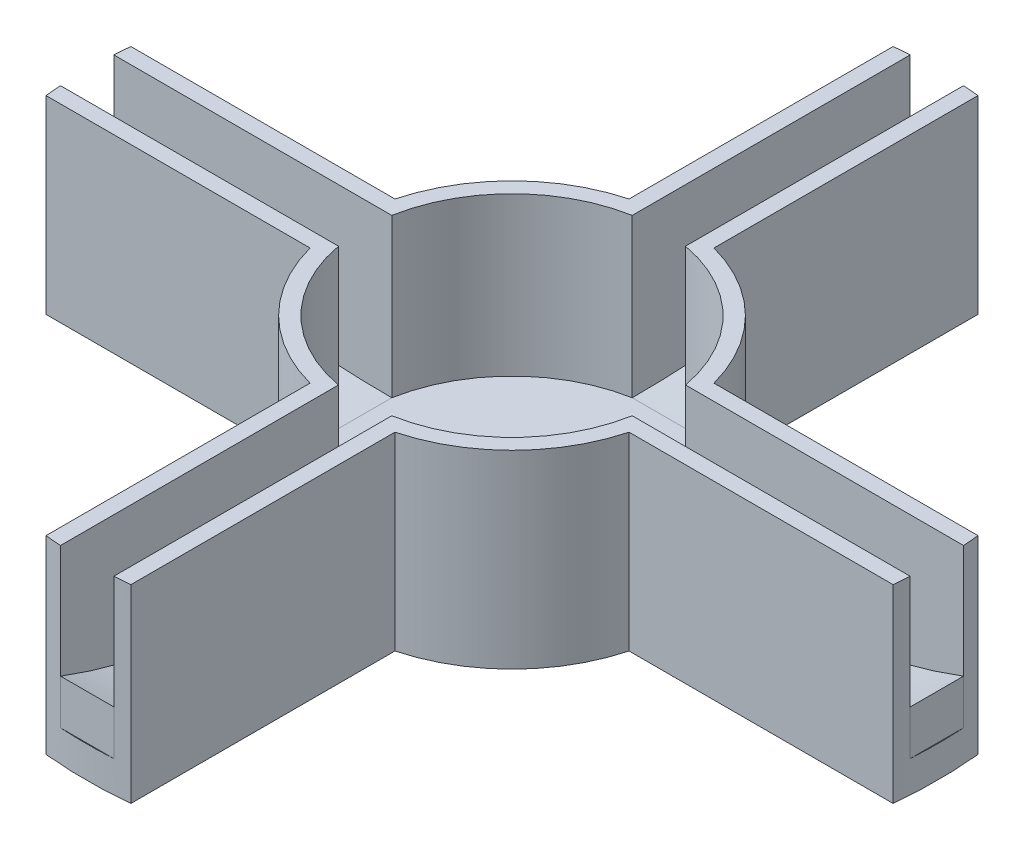
from build123d import *

# Parameters (mm, degrees)
SKETCH2_R           = 26.95
SKETCH2_R_2         = 9.45
BOSS_EXTRUDE2_DEPTH = 10
SKETCH3_R           = 26.95
BOSS_EXTRUDE3_DEPTH = 2
CUT_EXTRUDE1_DEPTH  = 10
BOSS_EXTRUDE4_DEPTH = 3.375
CIRPATTERN1_COUNT   = 4
CUT_EXTRUDE2_DEPTH  = 12
CIRPATTERN2_COUNT   = 4


with BuildPart() as part:
    # Sketch2 → Boss-Extrude2 (new body)
    with BuildSketch(Plane(origin=(0, 0, 0), x_dir=(1, 0, 0), z_dir=(0, 1, 0))):
        Circle(SKETCH2_R)
        Circle(SKETCH2_R_2, mode=Mode.SUBTRACT)
    extrude(amount=BOSS_EXTRUDE2_DEPTH)

    # Sketch3 → Boss-Extrude3 (add)
    with BuildSketch(Plane.XZ):
        Circle(SKETCH3_R)
    extrude(amount=BOSS_EXTRUDE3_DEPTH)

    # Sketch4 → Cut-Extrude1 (cut)
    with BuildSketch(Plane(origin=(0, 10, 0), x_dir=(1, 0, 0), z_dir=(0, 1, 0))):
        with BuildLine():
            Line((-1.6875, 26.8971159), (-1.6875, 9.298109687))
            ThreePointArc((-1.6875, 9.298109687), (0, 9.45), (1.6875, 9.298109687))
            Line((1.6875, 9.298109687), (1.6875, 26.8971159))
            ThreePointArc((1.6875, 26.8971159), (0, 26.95), (-1.6875, 26.8971159))
        make_face()
    cut_extrude1 = extrude(amount=-CUT_EXTRUDE1_DEPTH, mode=Mode.SUBTRACT)

    # Sketch7 → Boss-Extrude4 (add)
    with BuildSketch(Plane(origin=(-1.6875, 0, 0), x_dir=(0, 0, -1), z_dir=(1, 0, 0))):
        with BuildLine():
            Line((26.8971159, 0), (26.8971159, 2.834046352))
            add(Edge.make_bspline(
                [(9.298109687, 0), (19.523797501, 0), (26.8971159, 2.834046352)],
                knots=[4.71238898, 4.71238898, 4.71238898, 5.477856607, 5.477856607, 5.477856607], degree=2, weights=[1, 0.927647139, 1]))
            Line((9.298109687, 0), (26.8971159, 0))
        make_face()
    boss_extrude4 = extrude(amount=BOSS_EXTRUDE4_DEPTH)

    # CirPattern1: Cut-Extrude1, Boss-Extrude4 ×4 about axis
    cirpattern1_axis = Axis((0, 10, 0), (0, -1, 0))
    for i in range(1, CIRPATTERN1_COUNT):
        add(cut_extrude1.rotate(cirpattern1_axis, i * 360 / CIRPATTERN1_COUNT), mode=Mode.SUBTRACT)
        add(boss_extrude4.rotate(cirpattern1_axis, i * 360 / CIRPATTERN1_COUNT))

    # Sketch6 → Cut-Extrude2 (cut)
    with BuildSketch(Plane(origin=(0, 10, 0), x_dir=(1, 0, 0), z_dir=(0, 1, 0))):
        with BuildLine():
            Line((-26.815664149, 2.6875), (-10.098507006, 2.6875))
            ThreePointArc((-10.098507006, 2.6875), (-7.389265863, 7.389265863), (-2.6875, 10.098507006))
            Line((-2.6875, 10.098507006), (-2.6875, 26.815664149))
            ThreePointArc((-2.6875, 26.815664149), (-19.056527753, 19.056527753), (-26.815664149, 2.6875))
        make_face()
    cut_extrude2 = extrude(amount=-CUT_EXTRUDE2_DEPTH, mode=Mode.SUBTRACT)

    # CirPattern2: Cut-Extrude2 ×4 about axis
    cirpattern2_axis = Axis((0, 0, 0), (0, 1, 0))
    for i in range(1, CIRPATTERN2_COUNT):
        add(cut_extrude2.rotate(cirpattern2_axis, i * 360 / CIRPATTERN2_COUNT), mode=Mode.SUBTRACT)


solid = part.part
